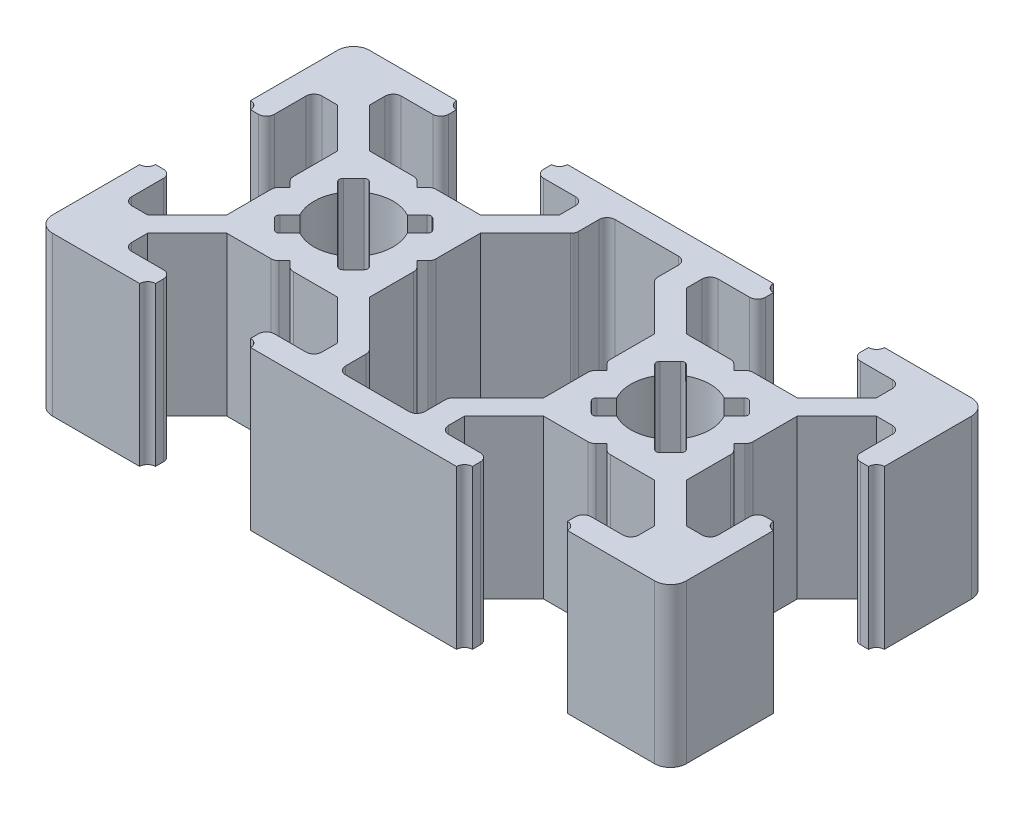
from build123d import *

# Parameters (mm, degrees)
BOSS_EXTRUDE1_DEPTH = 10
FILLET1_R           = 1
FILLET2_R           = 0.5
FILLET3_R           = 0.25
FILLET5_R           = 0.25
FILLET6_R           = 0.5
FILLET7_R           = 0.5
FILLET8_R           = 0.5


with BuildPart() as part:
    # Sketch2 → Boss-Extrude1 (new body)
    with BuildSketch(Plane(origin=(0, 0, 0), x_dir=(1, 0, 0), z_dir=(0, 1, 0))):
        with BuildLine():
            ThreePointArc((0, 13.5), (0.353553391, 13.353553391), (0.5, 13))
            Line((0.5, 13), (1.5, 13))
            Line((1.5, 13), (1.5, 16))
            Line((1.5, 16), (3, 16))
            Line((3, 16), (5.5, 13.5))
            Line((5.5, 13.5), (5.5, 10.5))
            Line((5.5, 10.5), (6, 10))
            Line((6, 10), (5.5, 9.5))
            Line((5.5, 9.5), (5.5, 6.5))
            Line((5.5, 6.5), (3, 4))
            Line((3, 4), (1.5, 4))
            Line((1.5, 4), (1.5, 7))
            Line((1.5, 7), (0.5, 7))
            ThreePointArc((0.5, 7), (0.353553391, 6.646446609), (0, 6.5))
            Line((0, 6.5), (0, 0))
            Line((0, 0), (6.5, 0))
            ThreePointArc((6.5, 0), (6.646446609, 0.353553391), (7, 0.5))
            Line((7, 0.5), (7, 1.5))
            Line((7, 1.5), (4, 1.5))
            Line((4, 1.5), (4, 3))
            Line((4, 3), (6.5, 5.5))
            Line((6.5, 5.5), (9.5, 5.5))
            Line((9.5, 5.5), (10, 6))
            Line((10, 6), (10.5, 5.5))
            Line((10.5, 5.5), (13.5, 5.5))
            Line((13.5, 5.5), (16, 3))
            Line((16, 3), (16, 1.5))
            Line((16, 1.5), (13, 1.5))
            Line((13, 1.5), (13, 0.5))
            ThreePointArc((13, 0.5), (13.353553391, 0.353553391), (13.5, 0))
            Line((13.5, 0), (26.5, 0))
            ThreePointArc((26.5, 0), (26.646446609, 0.353553391), (27, 0.5))
            Line((27, 0.5), (27, 1.5))
            Line((27, 1.5), (24, 1.5))
            Line((24, 1.5), (24, 3))
            Line((24, 3), (26.5, 5.5))
            Line((26.5, 5.5), (29.5, 5.5))
            Line((29.5, 5.5), (30, 6))
            Line((30, 6), (30.5, 5.5))
            Line((30.5, 5.5), (33.5, 5.5))
            Line((33.5, 5.5), (36, 3))
            Line((36, 3), (36, 1.5))
            Line((36, 1.5), (33, 1.5))
            Line((33, 1.5), (33, 0.5))
            ThreePointArc((33, 0.5), (33.353553391, 0.353553391), (33.5, 0))
            Line((33.5, 0), (40, 0))
            Line((40, 0), (40, 6.5))
            ThreePointArc((40, 6.5), (39.646446609, 6.646446609), (39.5, 7))
            Line((39.5, 7), (38.5, 7))
            Line((38.5, 7), (38.5, 4))
            Line((38.5, 4), (37, 4))
            Line((37, 4), (34.5, 6.5))
            Line((34.5, 6.5), (34.5, 9.5))
            Line((34.5, 9.5), (34, 10))
            Line((34, 10), (34.5, 10.5))
            Line((34.5, 10.5), (34.5, 13.5))
            Line((34.5, 13.5), (37, 16))
            Line((37, 16), (38.5, 16))
            Line((38.5, 16), (38.5, 13))
            Line((38.5, 13), (39.5, 13))
            ThreePointArc((39.5, 13), (39.646446609, 13.353553391), (40, 13.5))
            Line((40, 13.5), (40, 20))
            Line((40, 20), (33.5, 20))
            ThreePointArc((33.5, 20), (33.353553391, 19.646446609), (33, 19.5))
            Line((33, 19.5), (33, 18.5))
            Line((33, 18.5), (36, 18.5))
            Line((36, 18.5), (36, 17))
            Line((36, 17), (33.5, 14.5))
            Line((33.5, 14.5), (30.5, 14.5))
            Line((30.5, 14.5), (30, 14))
            Line((30, 14), (29.5, 14.5))
            Line((29.5, 14.5), (26.5, 14.5))
            Line((26.5, 14.5), (24, 17))
            Line((24, 17), (24, 18.5))
            Line((24, 18.5), (27, 18.5))
            Line((27, 18.5), (27, 19.5))
            ThreePointArc((27, 19.5), (26.646446609, 19.646446609), (26.5, 20))
            Line((26.5, 20), (13.5, 20))
            ThreePointArc((13.5, 20), (13.353553391, 19.646446609), (13, 19.5))
            Line((13, 19.5), (13, 18.5))
            Line((13, 18.5), (16, 18.5))
            Line((16, 18.5), (16, 17))
            Line((16, 17), (13.5, 14.5))
            Line((13.5, 14.5), (10.5, 14.5))
            Line((10.5, 14.5), (10, 14))
            Line((10, 14), (9.5, 14.5))
            Line((9.5, 14.5), (6.5, 14.5))
            Line((6.5, 14.5), (4, 17))
            Line((4, 17), (4, 18.5))
            Line((4, 18.5), (7, 18.5))
            Line((7, 18.5), (7, 19.5))
            ThreePointArc((7, 19.5), (6.646446609, 19.646446609), (6.5, 20))
            Line((6.5, 20), (0, 20))
            Line((0, 20), (0, 13.5))
        make_face()
        with BuildLine():
            Line((11.195582496, 12.195582496), (12, 13))
            Line((12, 13), (13, 12))
            Line((13, 12), (12.195582496, 11.195582496))
            ThreePointArc((12.195582496, 11.195582496), (12.422700584, 10.616864556), (12.5, 10))
            ThreePointArc((12.5, 10), (12.422700584, 9.383135444), (12.195582496, 8.804417504))
            Line((12.195582496, 8.804417504), (13, 8))
            Line((13, 8), (12, 7))
            Line((12, 7), (11.195582496, 7.804417504))
            ThreePointArc((11.195582496, 7.804417504), (10, 7.5), (8.804417504, 7.804417504))
            Line((8.804417504, 7.804417504), (8, 7))
            Line((8, 7), (7, 8))
            Line((7, 8), (7.804417504, 8.804417504))
            ThreePointArc((7.804417504, 8.804417504), (7.5, 10), (7.804417504, 11.195582496))
            Line((7.804417504, 11.195582496), (7, 12))
            Line((7, 12), (8, 13))
            Line((8, 13), (8.804417504, 12.195582496))
            ThreePointArc((8.804417504, 12.195582496), (10, 12.5), (11.195582496, 12.195582496))
        make_face(mode=Mode.SUBTRACT)
        Polygon((17.5, 16.5), (17.5, 18.5), (22.5, 18.5), (22.5, 16.5), (25.5, 13.5), (25.5, 10.5), (26, 10), (25.5, 9.5), (25.5, 6.5), (22.5, 3.5), (22.5, 1.5), (17.5, 1.5), (17.5, 3.5), (14.5, 6.5), (14.5, 9.5), (14, 10), (14.5, 10.5), (14.5, 13.5), align=None, mode=Mode.SUBTRACT)
        with BuildLine():
            Line((28.804417504, 7.804417504), (28, 7))
            Line((28, 7), (27, 8))
            Line((27, 8), (27.804417504, 8.804417504))
            ThreePointArc((27.804417504, 8.804417504), (27.5, 10), (27.804417504, 11.195582496))
            Line((27.804417504, 11.195582496), (27, 12))
            Line((27, 12), (28, 13))
            Line((28, 13), (28.804417504, 12.195582496))
            ThreePointArc((28.804417504, 12.195582496), (30, 12.5), (31.195582496, 12.195582496))
            Line((31.195582496, 12.195582496), (32, 13))
            Line((32, 13), (33, 12))
            Line((33, 12), (32.195582496, 11.195582496))
            ThreePointArc((32.195582496, 11.195582496), (32.422700584, 10.616864556), (32.5, 10))
            ThreePointArc((32.5, 10), (32.422700584, 9.383135444), (32.195582496, 8.804417504))
            Line((32.195582496, 8.804417504), (33, 8))
            Line((33, 8), (32, 7))
            Line((32, 7), (31.195582496, 7.804417504))
            ThreePointArc((31.195582496, 7.804417504), (30, 7.5), (28.804417504, 7.804417504))
        make_face(mode=Mode.SUBTRACT)
    extrude(amount=BOSS_EXTRUDE1_DEPTH)

    # Fillet1
    fillet1_edges = [part.edges().sort_by_distance(p)[0] for p in [
        (40, 5, 0),
        (0, 5, 0),
        (0, 5, -20),
        (40, 5, -20),
    ]]
    fillet(fillet1_edges, radius=FILLET1_R)

    # Fillet2
    fillet2_edges = [part.edges().sort_by_distance(p)[0] for p in [
        (7, 5, -18.5),
        (4, 5, -18.5),
        (9.5, 5, -14.5),
        (10.5, 5, -14.5),
        (16, 5, -18.5),
        (13, 5, -18.5),
    ]]
    fillet(fillet2_edges, radius=FILLET2_R)

    # Fillet3
    fillet3_edges = [part.edges().sort_by_distance(p)[0] for p in [
        (13, 5, -12),
        (12, 5, -13),
        (8, 5, -13),
        (7, 5, -12),
        (7, 5, -8),
        (8, 5, -7),
        (12, 5, -7),
        (13, 5, -8),
    ]]
    fillet(fillet3_edges, radius=FILLET3_R)

    # Fillet5
    fillet5_edges = [part.edges().sort_by_distance(p)[0] for p in [
        (27, 5, -8),
        (28, 5, -7),
        (32, 5, -7),
        (33, 5, -8),
        (33, 5, -12),
        (32, 5, -13),
        (28, 5, -13),
        (27, 5, -12),
    ]]
    fillet(fillet5_edges, radius=FILLET5_R)

    # Fillet6
    fillet6_edges = [part.edges().sort_by_distance(p)[0] for p in [
        (33, 5, -1.5),
        (36, 5, -1.5),
        (30.5, 5, -5.5),
        (29.5, 5, -5.5),
        (24, 5, -1.5),
        (27, 5, -1.5),
        (13, 5, -1.5),
        (16, 5, -1.5),
        (10.5, 5, -5.5),
        (9.5, 5, -5.5),
        (4, 5, -1.5),
        (7, 5, -1.5),
        (1.5, 5, -7),
        (1.5, 5, -4),
        (5.5, 5, -9.5),
        (5.5, 5, -10.5),
        (1.5, 5, -16),
        (1.5, 5, -13),
        (27, 5, -18.5),
        (24, 5, -18.5),
        (29.5, 5, -14.5),
        (30.5, 5, -14.5),
        (36, 5, -18.5),
        (33, 5, -18.5),
        (38.5, 5, -13),
        (38.5, 5, -16),
        (34.5, 5, -10.5),
        (34.5, 5, -9.5),
        (38.5, 5, -4),
        (38.5, 5, -7),
    ]]
    fillet(fillet6_edges, radius=FILLET6_R)

    # Fillet7
    fillet7_edges = [part.edges().sort_by_distance(p)[0] for p in [
        (22.5, 5, -16.5),
        (22.5, 5, -18.5),
        (17.5, 5, -18.5),
        (17.5, 5, -16.5),
        (17.5, 5, -3.5),
        (17.5, 5, -1.5),
        (22.5, 5, -1.5),
        (22.5, 5, -3.5),
    ]]
    fillet(fillet7_edges, radius=FILLET7_R)

    # Fillet8
    fillet8_edges = [part.edges().sort_by_distance(p)[0] for p in [
        (25.5, 5, -10.5),
        (14.5, 5, -10.5),
        (14.5, 5, -9.5),
        (25.5, 5, -9.5),
    ]]
    fillet(fillet8_edges, radius=FILLET8_R)


solid = part.part
